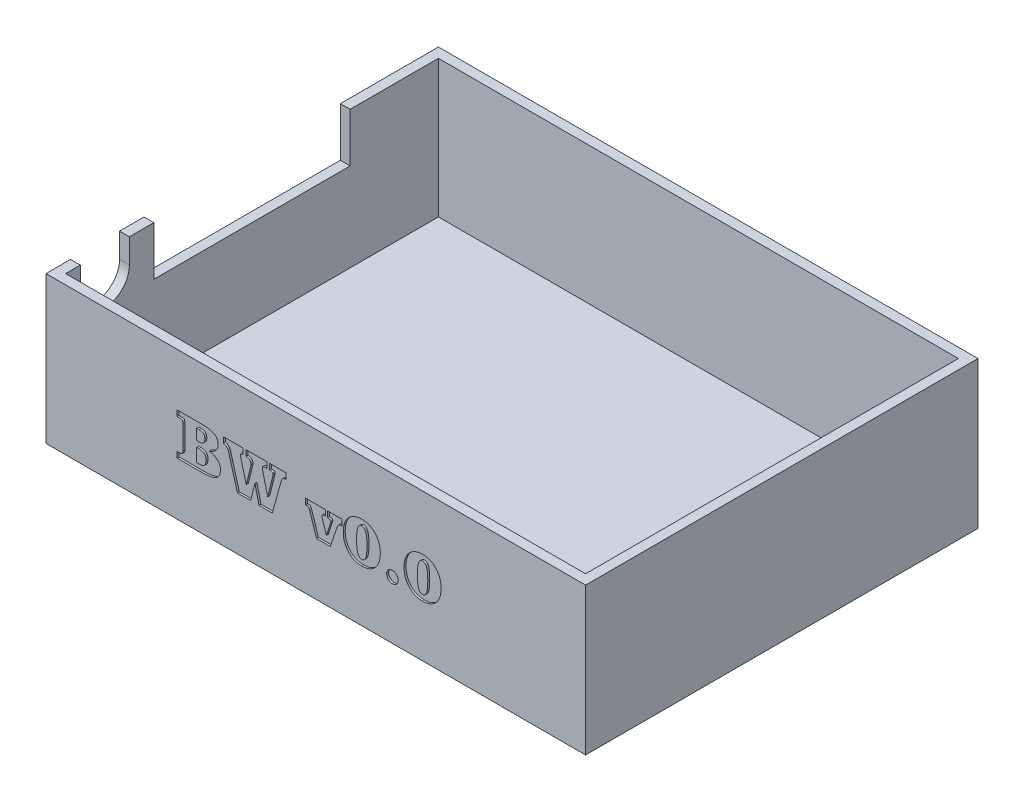
from build123d import *

# Parameters (mm, degrees)
SKETCH1_W           = 110
SKETCH1_H           = 80
BOSS_EXTRUDE1_DEPTH = 30
SHELL1_T            = -2
CUT_EXTRUDE1_REACH  = 112
SKETCH15_W          = 40
SKETCH15_H          = 10
CUT_EXTRUDE2_REACH  = 112
CUT_EXTRUDE3_DEPTH  = 0.4


with BuildPart() as part:
    # Sketch1 → Boss-Extrude1 (new body)
    with BuildSketch(Plane(origin=(0, 0, 0), x_dir=(1, 0, 0), z_dir=(0, 1, 0))):
        with Locations((55, 40)):
            Rectangle(SKETCH1_W, SKETCH1_H)
    extrude(amount=BOSS_EXTRUDE1_DEPTH)

    # Shell1
    shell1_openings = [part.faces().sort_by_distance(p)[0] for p in [
        (55, 30, -40),
    ]]
    offset(amount=SHELL1_T, openings=shell1_openings, kind=Kind.INTERSECTION)

    # Sketch15 → Cut-Extrude1 (cut, up to next)
    with BuildSketch(Plane.ZY, mode=Mode.PRIVATE) as cut_extrude1_sk1:
        with Locations((-40, 25)):
            Rectangle(SKETCH15_W, SKETCH15_H)
    cut_extrude1_tool1 = extrude(cut_extrude1_sk1.sketch, amount=-CUT_EXTRUDE1_REACH, mode=Mode.PRIVATE) & part.part
    add(cut_extrude1_tool1.solids().sort_by_distance((0, 25, -40))[0], mode=Mode.SUBTRACT)

    # Sketch17 → Cut-Extrude2 (cut, up to next)
    with BuildSketch(Plane.ZY, mode=Mode.PRIVATE) as cut_extrude2_sk1:
        with BuildLine():
            Line((-5, 25), (-5, 30))
            Line((-5, 30), (-15, 30))
            Line((-15, 30), (-15, 25))
            ThreePointArc((-15, 25), (-10, 20), (-5, 25))
        make_face()
    cut_extrude2_tool1 = extrude(cut_extrude2_sk1.sketch, amount=-CUT_EXTRUDE2_REACH, mode=Mode.PRIVATE) & part.part
    add(cut_extrude2_tool1.solids().sort_by_distance((0, 25.466749, -10))[0], mode=Mode.SUBTRACT)

    # Sketch19 → Cut-Extrude3 (cut)
    with BuildSketch(Plane.XY):
        with BuildLine():
            Line((26.714769787, 10.78656484), (26.714769787, 11.980032722))
            Line((26.714769787, 11.980032722), (27.16670121, 11.980032722))
            add(Edge.make_bspline(
                [(27.16670121, 11.980032722), (27.235036267, 11.980341078), (27.359170057, 11.980901222), (27.525767484, 12.002206712), (27.655496277, 12.027902602), (27.757390003, 12.072839446), (27.82752873, 12.159463619), (27.867385276, 12.285759373), (27.891107838, 12.453780677), (27.893814382, 12.580648302), (27.895325342, 12.651473694)],
                knots=[0, 0, 0, 0, 0.000204827, 0.000372078, 0.000502734, 0.000601727, 0.000698565, 0.000826377, 0.000994389, 0.001206721, 0.001206721, 0.001206721, 0.001206721], degree=3))
            Line((27.895325342, 12.651473694), (27.895325342, 12.714190708))
            Line((27.895325342, 12.714190708), (27.895325342, 17.399520569))
            add(Edge.make_bspline(
                [(27.895325342, 17.399520569), (27.894633353, 17.472179333), (27.893384356, 17.603323647), (27.868731245, 17.776515565), (27.831793135, 17.906345783), (27.769557231, 18.000539309), (27.667544151, 18.052053507), (27.533936365, 18.084063364), (27.357746728, 18.102291212), (27.226371785, 18.104686126), (27.153788884, 18.106009285)],
                knots=[0, 0, 0, 0, 0.00021779, 0.000393097, 0.000523178, 0.00062096, 0.000720945, 0.000856521, 0.001032931, 0.001250721, 0.001250721, 0.001250721, 0.001250721], degree=3))
            Line((27.153788884, 18.106009285), (26.714769787, 18.106009285))
            Line((26.714769787, 18.106009285), (26.714769787, 19.28656484))
            Line((26.714769787, 19.28656484), (31.857564926, 19.28656484))
            add(Edge.make_bspline(
                [(31.857564926, 19.28656484), (31.992257434, 19.285256135), (32.253226736, 19.282720495), (32.630489994, 19.260285256), (32.98051086, 19.225060022), (33.301647483, 19.17063196), (33.596445836, 19.106368052), (33.861940887, 19.023004466), (34.101219841, 18.927745549), (34.312454752, 18.815453835), (34.498439525, 18.686326055), (34.660278143, 18.541458122), (34.794000196, 18.375714122), (34.906670416, 18.196361763), (34.990564187, 17.997774513), (35.055229769, 17.784266098), (35.088599224, 17.551817585), (35.09395615, 17.391616063), (35.096714231, 17.309134285)],
                knots=[0, 0, 0, 0, 0.000404039, 0.000782833, 0.001133412, 0.001458803, 0.001759521, 0.002037814, 0.002292665, 0.002531164, 0.002753759, 0.002970531, 0.003180267, 0.003390659, 0.003603806, 0.003825014, 0.00405824, 0.004305755, 0.004305755, 0.004305755, 0.004305755], degree=3))
            add(Edge.make_bspline(
                [(35.096714231, 17.309134285), (35.095383355, 17.251868314), (35.092754336, 17.138744862), (35.069241365, 16.972276946), (35.035210863, 16.811430624), (34.984764193, 16.65613805), (34.918166047, 16.507751202), (34.838655463, 16.365078213), (34.745097156, 16.228378213), (34.636566194, 16.098548136), (34.515050542, 15.975123594), (34.380277332, 15.859515195), (34.232872869, 15.75110716), (34.072743877, 15.649748059), (33.89896586, 15.557304477), (33.714001293, 15.470771917), (33.514607859, 15.393065418), (33.376525485, 15.347653944), (33.305590099, 15.324325257)],
                knots=[0, 0, 0, 0, 0.000171708, 0.000339193, 0.000503457, 0.000664458, 0.000827964, 0.000990646, 0.001153861, 0.001324146, 0.001497629, 0.001672897, 0.001856258, 0.002046119, 0.00224089, 0.002446381, 0.002658416, 0.002882413, 0.002882413, 0.002882413, 0.002882413], degree=3))
            add(Edge.make_bspline(
                [(33.305590099, 15.324325257), (33.398119091, 15.303972249), (33.578281699, 15.264343036), (33.836139297, 15.187165882), (34.077792257, 15.105350011), (34.299927869, 15.011410982), (34.504541052, 14.90932463), (34.691957585, 14.800246424), (34.857838276, 14.676532304), (35.009563144, 14.548246607), (35.140484262, 14.406588081), (35.255936615, 14.257259066), (35.353018069, 14.096346414), (35.43228044, 13.925019269), (35.492799177, 13.742874368), (35.537757894, 13.551629801), (35.563407312, 13.349435625), (35.567065156, 13.211078749), (35.568936453, 13.140297479)],
                knots=[0, 0, 0, 0, 0.000284125, 0.000553218, 0.000806979, 0.001049193, 0.001276051, 0.001492753, 0.001698624, 0.001896102, 0.002087951, 0.002276111, 0.002461493, 0.002650492, 0.002841238, 0.003036323, 0.003239038, 0.00345137, 0.00345137, 0.00345137, 0.00345137], degree=3))
            add(Edge.make_bspline(
                [(35.568936453, 13.140297479), (35.566975999, 13.03867375), (35.563178896, 12.84184395), (35.5193464, 12.55868263), (35.451555252, 12.297256854), (35.356739614, 12.057052988), (35.228514673, 11.841380844), (35.077435572, 11.645243502), (34.895495241, 11.47417459), (34.685714891, 11.324824868), (34.442878212, 11.196564383), (34.164751657, 11.087094513), (33.849799806, 10.993962902), (33.497894129, 10.916627686), (33.108229669, 10.859334434), (32.681622835, 10.817602654), (32.218195873, 10.791765955), (31.89695161, 10.788341492), (31.73028628, 10.78656484)],
                knots=[0, 0, 0, 0, 0.000304636, 0.000590033, 0.000857147, 0.001113708, 0.001361739, 0.001607488, 0.001854095, 0.002107983, 0.00237784, 0.002675848, 0.00300324, 0.003362178, 0.003755843, 0.004184057, 0.004647776, 0.005147752, 0.005147752, 0.005147752, 0.005147752], degree=3))
            Line((31.73028628, 10.78656484), (26.714769787, 10.78656484))
        make_face()
        with BuildLine():
            Line((30.728658676, 11.967120396), (31.241462495, 11.967120396))
            add(Edge.make_bspline(
                [(31.241462495, 11.967120396), (31.30051387, 11.968317745), (31.415117069, 11.970641485), (31.580479253, 11.984579937), (31.732706013, 12.010676713), (31.87162286, 12.045424665), (31.998223504, 12.089161674), (32.111880992, 12.144536301), (32.211910094, 12.211456878), (32.300969919, 12.288077945), (32.37637685, 12.377678255), (32.44271057, 12.478730252), (32.494639248, 12.594743557), (32.541345666, 12.721288653), (32.57646004, 12.861638957), (32.599250492, 13.014867074), (32.614304462, 13.181198901), (32.616441099, 13.296439861), (32.617547565, 13.356117792)],
                knots=[0, 0, 0, 0, 0.00017717, 0.00034384, 0.000497287, 0.000640004, 0.000773021, 0.000898415, 0.00101813, 0.001133179, 0.001249624, 0.001368326, 0.001494585, 0.00162996, 0.001772677, 0.001927647, 0.002094317, 0.00227333, 0.00227333, 0.00227333, 0.00227333], degree=3))
            add(Edge.make_bspline(
                [(32.617547565, 13.356117792), (32.616321155, 13.410861647), (32.613946368, 13.516866247), (32.600373543, 13.670766056), (32.572001556, 13.813080324), (32.53513352, 13.944446943), (32.490604703, 14.065869514), (32.429458409, 14.173338326), (32.3618981, 14.272315329), (32.281735744, 14.359806332), (32.189981564, 14.435789224), (32.088288935, 14.502848948), (31.973888931, 14.558098498), (31.848068677, 14.604681559), (31.709236856, 14.63844973), (31.559584269, 14.664753227), (31.397911653, 14.678970118), (31.286373176, 14.681227775), (31.228550169, 14.682398174)],
                knots=[0, 0, 0, 0, 0.000164264, 0.000318077, 0.000462783, 0.000598847, 0.00072731, 0.000849501, 0.000968733, 0.001086239, 0.001204093, 0.001325348, 0.001450741, 0.001584384, 0.0017271, 0.00187873, 0.002039889, 0.002213371, 0.002213371, 0.002213371, 0.002213371], degree=3))
            Line((31.228550169, 14.682398174), (30.728658676, 14.682398174))
            Line((30.728658676, 14.682398174), (30.728658676, 11.967120396))
        make_face(mode=Mode.SUBTRACT)
        with BuildLine():
            Line((30.728658676, 15.862953729), (31.165833155, 15.862953729))
            add(Edge.make_bspline(
                [(31.165833155, 15.862953729), (31.216895862, 15.863470322), (31.315511541, 15.864468002), (31.458560146, 15.877532229), (31.590441668, 15.899424437), (31.712205294, 15.928783842), (31.823171545, 15.96698828), (31.923006349, 16.015360879), (32.013017414, 16.070489922), (32.117420831, 16.157889234), (32.227104505, 16.294185495), (32.320409995, 16.495659036), (32.371794332, 16.736011605), (32.378094027, 16.907991266), (32.381436453, 16.999238451)],
                knots=[0, 0, 0, 0, 0.000153148, 0.000295769, 0.000430414, 0.000553893, 0.000671153, 0.000781707, 0.00088612, 0.000986968, 0.001188918, 0.001405108, 0.001647204, 0.00192083, 0.00192083, 0.00192083, 0.00192083], degree=3))
            add(Edge.make_bspline(
                [(32.381436453, 16.999238451), (32.378949196, 17.089309413), (32.37430039, 17.25765645), (32.322753356, 17.490478007), (32.239229428, 17.68427574), (32.136416255, 17.813879048), (32.036518675, 17.892092697), (31.952687696, 17.945417433), (31.855657682, 17.986606469), (31.747732357, 18.022105474), (31.628397901, 18.04870623), (31.497900779, 18.069715851), (31.355993406, 18.07991448), (31.257461079, 18.081307548), (31.206414752, 18.08202925)],
                knots=[0, 0, 0, 0, 0.000269825, 0.000504317, 0.000710716, 0.000898261, 0.000992751, 0.001090516, 0.0011954, 0.001307982, 0.001431034, 0.001561741, 0.001704208, 0.001857355, 0.001857355, 0.001857355, 0.001857355], degree=3))
            Line((31.206414752, 18.08202925), (30.728658676, 18.08202925))
            Line((30.728658676, 18.08202925), (30.728658676, 15.862953729))
        make_face(mode=Mode.SUBTRACT)
        with BuildLine():
            Line((40.17310312, 19.28656484), (40.17310312, 18.106009285))
            add(Edge.make_bspline(
                [(40.17310312, 18.106009285), (40.126963818, 18.104746399), (40.041860154, 18.102417015), (39.924146066, 18.090949668), (39.827968582, 18.068350193), (39.752406155, 18.034831459), (39.694736375, 17.990612218), (39.654988496, 17.932591364), (39.630032122, 17.86198193), (39.628112903, 17.810483171), (39.627096176, 17.783201125)],
                knots=[0, 0, 0, 0, 0.000138457, 0.000255383, 0.000354255, 0.000433488, 0.000501764, 0.000569313, 0.000641654, 0.000723152, 0.000723152, 0.000723152, 0.000723152], degree=3))
            add(Edge.make_bspline(
                [(39.627096176, 17.783201125), (39.627965417, 17.754283116), (39.629689643, 17.696921413), (39.638547185, 17.612284069), (39.654964207, 17.531435606), (39.670951632, 17.479955564), (39.678745481, 17.454859111)],
                knots=[0, 0, 0, 0, 8.6776e-05, 0.000172128, 0.000254971, 0.000333774, 0.000333774, 0.000333774, 0.000333774], degree=3))
            Line((39.678745481, 17.454859111), (40.831631766, 13.136608243))
            Line((40.831631766, 13.136608243), (41.829570134, 17.163409458))
            add(Edge.make_bspline(
                [(41.829570134, 17.163409458), (41.812939889, 17.248074658), (41.782172869, 17.404710715), (41.713759846, 17.6154942), (41.628532419, 17.782124284), (41.521051327, 17.908957992), (41.382395008, 17.997746063), (41.209133808, 18.055943704), (40.999453087, 18.096594811), (40.846004924, 18.102714268), (40.763380898, 18.106009285)],
                knots=[0, 0, 0, 0, 0.000258701, 0.000478613, 0.000662641, 0.000816906, 0.000971414, 0.001149971, 0.001362327, 0.001610062, 0.001610062, 0.001610062, 0.001610062], degree=3))
            Line((40.763380898, 18.106009285), (40.763380898, 19.28656484))
            Line((40.763380898, 19.28656484), (45.013380898, 19.28656484))
            Line((45.013380898, 19.28656484), (45.013380898, 18.106009285))
            Line((45.013380898, 18.106009285), (44.731154335, 18.106009285))
            add(Edge.make_bspline(
                [(44.731154335, 18.106009285), (44.672695696, 18.105869823), (44.565998333, 18.105615279), (44.421674322, 18.09046751), (44.307991602, 18.070410238), (44.221411853, 18.040620894), (44.160957874, 17.994166189), (44.118182543, 17.936502731), (44.094234429, 17.863635925), (44.092166565, 17.81104299), (44.09107187, 17.783201125)],
                knots=[0, 0, 0, 0, 0.000175278, 0.000319913, 0.000434591, 0.000521601, 0.000591332, 0.000659956, 0.000734039, 0.000817374, 0.000817374, 0.000817374, 0.000817374], degree=3))
            add(Edge.make_bspline(
                [(44.09107187, 17.783201125), (44.091376854, 17.760441782), (44.092004877, 17.713575818), (44.099267837, 17.63927741), (44.118663576, 17.552914186), (44.133981571, 17.490480393), (44.142721176, 17.454859111)],
                knots=[0, 0, 0, 0, 6.8276e-05, 0.000140593, 0.000223437, 0.000333497, 0.000333497, 0.000333497, 0.000333497], degree=3))
            Line((44.142721176, 17.454859111), (45.194153467, 13.136608243))
            Line((45.194153467, 13.136608243), (46.27325503, 17.467771437))
            add(Edge.make_bspline(
                [(46.27325503, 17.467771437), (46.281092158, 17.497800516), (46.296029678, 17.55503576), (46.310237912, 17.638410047), (46.320162277, 17.713493258), (46.322138596, 17.761040407), (46.323059717, 17.783201125)],
                knots=[0, 0, 0, 0, 9.3057e-05, 0.000177367, 0.000253556, 0.000320065, 0.000320065, 0.000320065, 0.000320065], degree=3))
            add(Edge.make_bspline(
                [(46.323059717, 17.783201125), (46.321268115, 17.812256604), (46.317954152, 17.86600109), (46.294083077, 17.94151977), (46.248270351, 17.999812701), (46.182310366, 18.044507673), (46.088550452, 18.072259272), (45.961789012, 18.09328367), (45.795680326, 18.104755977), (45.671917809, 18.105563763), (45.603658676, 18.106009285)],
                knots=[0, 0, 0, 0, 8.7186e-05, 0.00016127, 0.000233588, 0.00030522, 0.000396803, 0.000524175, 0.000690692, 0.000895478, 0.000895478, 0.000895478, 0.000895478], degree=3))
            Line((45.603658676, 18.106009285), (45.603658676, 19.28656484))
            Line((45.603658676, 19.28656484), (48.909214231, 19.28656484))
            Line((48.909214231, 19.28656484), (48.909214231, 18.106009285))
            add(Edge.make_bspline(
                [(48.909214231, 18.106009285), (48.845091242, 18.104278351), (48.723143176, 18.10098649), (48.55225203, 18.066049532), (48.404889832, 18.009014243), (48.278299733, 17.927266337), (48.174845387, 17.811530447), (48.081644255, 17.66687669), (48.00226365, 17.486212518), (47.959749156, 17.352628755), (47.937100516, 17.281465014)],
                knots=[0, 0, 0, 0, 0.000192159, 0.000365445, 0.000520272, 0.000664034, 0.000812821, 0.000982175, 0.00117865, 0.001402648, 0.001402648, 0.001402648, 0.001402648], degree=3))
            Line((47.937100516, 17.281465014), (46.133064058, 10.78656484))
            Line((46.133064058, 10.78656484), (43.434387842, 10.78656484))
            Line((43.434387842, 10.78656484), (42.587708155, 14.254446785))
            Line((42.587708155, 14.254446785), (41.717048433, 10.78656484))
            Line((41.717048433, 10.78656484), (39.018372217, 10.78656484))
            Line((39.018372217, 10.78656484), (37.243849648, 17.050887757))
            add(Edge.make_bspline(
                [(37.243849648, 17.050887757), (37.216948412, 17.138330535), (37.166394506, 17.302656589), (37.065302076, 17.523145835), (36.958784365, 17.707937497), (36.833882431, 17.852735557), (36.693774166, 17.96358269), (36.533658472, 18.042633588), (36.353366761, 18.092960394), (36.225340845, 18.101564949), (36.159214231, 18.106009285)],
                knots=[0, 0, 0, 0, 0.00027416, 0.000515213, 0.000726218, 0.000911894, 0.001085327, 0.001258564, 0.001444294, 0.001642708, 0.001642708, 0.001642708, 0.001642708], degree=3))
            Line((36.159214231, 18.106009285), (36.159214231, 19.28656484))
            Line((36.159214231, 19.28656484), (40.17310312, 19.28656484))
        make_face()
        with BuildLine():
            add(Edge.make_bspline(
                [(58.032695134, 15.031030986), (58.039360552, 15.048713985), (58.052035815, 15.082340783), (58.06241358, 15.134063394), (58.070883869, 15.183849973), (58.071249986, 15.217299334), (58.071432113, 15.233938972)],
                knots=[0, 0, 0, 0, 5.6585e-05, 0.000107605, 0.000157953, 0.000207792, 0.000207792, 0.000207792, 0.000207792], degree=3))
            add(Edge.make_bspline(
                [(58.071432113, 15.233938972), (58.069896102, 15.263706906), (58.066970552, 15.320404159), (58.037974025, 15.399919178), (57.988955071, 15.46636349), (57.917473983, 15.517704372), (57.825639807, 15.557871132), (57.710253848, 15.59039149), (57.568522654, 15.613268348), (57.465245985, 15.622068293), (57.409214231, 15.626842618)],
                knots=[0, 0, 0, 0, 8.9021e-05, 0.000169553, 0.000249979, 0.000332987, 0.000430385, 0.000549474, 0.000691701, 0.00086038, 0.00086038, 0.00086038, 0.00086038], degree=3))
            Line((57.409214231, 15.626842618), (57.409214231, 16.807398174))
            Line((57.409214231, 16.807398174), (60.36060312, 16.807398174))
            Line((60.36060312, 16.807398174), (60.36060312, 15.621308764))
            Line((60.36060312, 15.621308764), (60.310798433, 15.621308764))
            add(Edge.make_bspline(
                [(60.310798433, 15.621308764), (60.25104752, 15.619701212), (60.137593109, 15.61664881), (59.976982035, 15.589588729), (59.836942366, 15.542236022), (59.715772728, 15.473684309), (59.611349784, 15.381843184), (59.520516271, 15.264189368), (59.439144503, 15.121365685), (59.397502173, 15.013852833), (59.375577078, 14.957246264)],
                knots=[0, 0, 0, 0, 0.000179166, 0.000340198, 0.000486621, 0.000620467, 0.000755124, 0.000900896, 0.001064486, 0.001246393, 0.001246393, 0.001246393, 0.001246393], degree=3))
            Line((59.375577078, 14.957246264), (57.933085759, 10.78656484))
            Line((57.933085759, 10.78656484), (55.149557113, 10.78656484))
            Line((55.149557113, 10.78656484), (53.756870481, 15.031030986))
            add(Edge.make_bspline(
                [(53.756870481, 15.031030986), (53.738671179, 15.089129634), (53.705550153, 15.19486374), (53.648740213, 15.33489642), (53.592283024, 15.441464547), (53.529460476, 15.517025388), (53.45698929, 15.566492446), (53.372054655, 15.599763204), (53.270545833, 15.61672147), (53.19800621, 15.619710384), (53.159214231, 15.621308764)],
                knots=[0, 0, 0, 0, 0.00018258, 0.000332278, 0.000452858, 0.000543093, 0.000623941, 0.000713344, 0.000814647, 0.000931091, 0.000931091, 0.000931091, 0.000931091], degree=3))
            Line((53.159214231, 15.621308764), (52.92310312, 15.621308764))
            Line((52.92310312, 15.621308764), (52.92310312, 16.807398174))
            Line((52.92310312, 16.807398174), (56.936992009, 16.807398174))
            Line((56.936992009, 16.807398174), (56.936992009, 15.621308764))
            Line((56.936992009, 15.621308764), (56.752530203, 15.621308764))
            add(Edge.make_bspline(
                [(56.752530203, 15.621308764), (56.708182232, 15.62118044), (56.626564938, 15.620944276), (56.514968575, 15.60516745), (56.422676373, 15.58532104), (56.349559953, 15.552064639), (56.29362927, 15.505349327), (56.256462104, 15.443683753), (56.233599051, 15.368315559), (56.23159061, 15.313447657), (56.230503294, 15.28374366)],
                knots=[0, 0, 0, 0, 0.000132864, 0.00024452, 0.000337578, 0.000415139, 0.000483165, 0.000552774, 0.000628042, 0.000716891, 0.000716891, 0.000716891, 0.000716891], degree=3))
            add(Edge.make_bspline(
                [(56.230503294, 15.28374366), (56.231329849, 15.265870006), (56.233110122, 15.227372907), (56.244912627, 15.166843296), (56.263776191, 15.100576226), (56.279466662, 15.054939019), (56.287686453, 15.031030986)],
                knots=[0, 0, 0, 0, 5.3621e-05, 0.000115491, 0.000184412, 0.000260244, 0.000260244, 0.000260244, 0.000260244], degree=3))
            Line((56.287686453, 15.031030986), (57.162035412, 12.36186866))
            Line((57.162035412, 12.36186866), (58.032695134, 15.031030986))
        make_face()
        with BuildLine():
            add(Edge.make_bspline(
                [(60.596714231, 14.678708937), (60.59995773, 14.830700288), (60.606290877, 15.127473478), (60.65408796, 15.56156039), (60.737241319, 15.971825304), (60.851705824, 16.359642126), (60.997477739, 16.725255984), (61.176709176, 17.068146352), (61.390575791, 17.387437775), (61.634994156, 17.681510663), (61.906226182, 17.946609076), (62.197275065, 18.181405427), (62.51314591, 18.375804464), (62.847112825, 18.537382828), (63.203444043, 18.660695877), (63.578037773, 18.752006028), (63.974639053, 18.803251246), (64.245226905, 18.810587756), (64.383715099, 18.814342618)],
                knots=[0, 0, 0, 0, 0.000455923, 0.00089022, 0.001308053, 0.001710184, 0.002101704, 0.002487022, 0.00286868, 0.003252471, 0.003632055, 0.004004832, 0.004371841, 0.004742284, 0.005115654, 0.005500865, 0.005897149, 0.006312598, 0.006312598, 0.006312598, 0.006312598], degree=3))
            add(Edge.make_bspline(
                [(64.383715099, 18.814342618), (64.520396855, 18.8108025), (64.788685622, 18.803853703), (65.181011122, 18.749176402), (65.553806715, 18.661110209), (65.906814332, 18.537356605), (66.239439467, 18.376151635), (66.550120173, 18.17633682), (66.844258379, 17.94532396), (67.113149552, 17.677542279), (67.359099187, 17.383677789), (67.571935463, 17.062907593), (67.750454148, 16.71971561), (67.900986912, 16.355793251), (68.010313902, 15.96691911), (68.095246563, 15.557991917), (68.142602435, 15.125604928), (68.148995378, 14.830076164), (68.152269787, 14.678708937)],
                knots=[0, 0, 0, 0, 0.00040992, 0.000804621, 0.001185815, 0.001557445, 0.001924566, 0.002291978, 0.002663608, 0.003044485, 0.003428276, 0.003811469, 0.004196786, 0.004587288, 0.00499067, 0.005406695, 0.005839159, 0.006293239, 0.006293239, 0.006293239, 0.006293239], degree=3))
            add(Edge.make_bspline(
                [(68.152269787, 14.678708937), (68.149002284, 14.527339576), (68.142622824, 14.231806642), (68.095170732, 13.79944941), (68.010702843, 13.390994166), (67.900214977, 13.002505405), (67.750875822, 12.638177326), (67.572461548, 12.294742063), (67.358384926, 11.975495312), (67.113895459, 11.681579541), (66.843423686, 11.416086624), (66.550218848, 11.183391245), (66.235838559, 10.98722493), (65.900027843, 10.82769743), (65.544921733, 10.701427753), (65.167578781, 10.613151274), (64.770060309, 10.561576316), (64.498233317, 10.554207968), (64.359735065, 10.550453729)],
                knots=[0, 0, 0, 0, 0.00045408, 0.000886543, 0.001302569, 0.001704179, 0.002096389, 0.002481707, 0.002863365, 0.003247156, 0.00362674, 0.00399837, 0.00436792, 0.004735902, 0.005111625, 0.005496408, 0.00589635, 0.006311798, 0.006311798, 0.006311798, 0.006311798], degree=3))
            add(Edge.make_bspline(
                [(64.359735065, 10.550453729), (64.223072958, 10.554185044), (63.954904695, 10.561506899), (63.562381861, 10.613456996), (63.189646462, 10.700882674), (62.838438121, 10.829113776), (62.504493687, 10.986094975), (62.192905805, 11.184042444), (61.90178169, 11.416664736), (61.631246032, 11.680930646), (61.38888144, 11.976135468), (61.174773435, 12.294727319), (60.995625304, 12.637710566), (60.849989139, 13.003330583), (60.735075707, 13.390327476), (60.65469898, 13.799777257), (60.606119408, 14.23175097), (60.59989984, 14.527320719), (60.596714231, 14.678708937)],
                knots=[0, 0, 0, 0, 0.00040992, 0.000804376, 0.001185569, 0.001556081, 0.001924062, 0.002290487, 0.002660672, 0.003040256, 0.003422871, 0.003804528, 0.004189846, 0.004581366, 0.004983497, 0.005399159, 0.005831622, 0.006285702, 0.006285702, 0.006285702, 0.006285702], degree=3))
        make_face()
        with BuildLine():
            add(Edge.make_bspline(
                [(65.436992009, 14.678708937), (65.436258015, 14.8041467), (65.434840091, 15.046466374), (65.424771754, 15.396538735), (65.403363104, 15.719306464), (65.379373677, 16.015509608), (65.34386187, 16.284302254), (65.303183579, 16.526752074), (65.250533404, 16.741205918), (65.19477678, 16.931316996), (65.128619654, 17.096514972), (65.052904282, 17.239662038), (64.965402295, 17.359521052), (64.872082048, 17.462221671), (64.764743451, 17.538991559), (64.648225521, 17.592893463), (64.522841353, 17.627938934), (64.435599585, 17.631811493), (64.391093571, 17.633787062)],
                knots=[0, 0, 0, 0, 0.00037632, 0.000726972, 0.001050418, 0.001346684, 0.001618269, 0.00186361, 0.002083731, 0.00228038, 0.002457473, 0.002616763, 0.002764724, 0.002901736, 0.003031254, 0.003157512, 0.003285484, 0.003418757, 0.003418757, 0.003418757, 0.003418757], degree=3))
            add(Edge.make_bspline(
                [(64.391093571, 17.633787062), (64.344818456, 17.631599496), (64.254836781, 17.627345786), (64.124068932, 17.595773944), (64.005113229, 17.538570553), (63.894235657, 17.462579471), (63.796417565, 17.362229473), (63.706448498, 17.242346153), (63.628250559, 17.099788605), (63.55978736, 16.935118948), (63.501070733, 16.745999969), (63.44988392, 16.530940419), (63.409265551, 16.288470726), (63.37124732, 16.019898701), (63.344408349, 15.723159145), (63.327590758, 15.398862898), (63.313179855, 15.047756543), (63.312397775, 14.80477502), (63.311992009, 14.678708937)],
                knots=[0, 0, 0, 0, 0.000138788, 0.000269873, 0.000400255, 0.000532785, 0.000671046, 0.000818615, 0.000981298, 0.001157389, 0.001352822, 0.001574737, 0.001820078, 0.00209008, 0.00238835, 0.002713526, 0.003064241, 0.003442406, 0.003442406, 0.003442406, 0.003442406], degree=3))
            add(Edge.make_bspline(
                [(63.311992009, 14.678708937), (63.312389926, 14.552641424), (63.313156876, 14.309657142), (63.327647049, 13.959183279), (63.344040248, 13.636046906), (63.372545378, 13.340246454), (63.40576742, 13.070942235), (63.451004526, 12.829410144), (63.498847402, 12.614265319), (63.558068701, 12.426028273), (63.62608776, 12.26205195), (63.703479684, 12.120645871), (63.79001804, 11.999966874), (63.889174918, 11.903684792), (63.99621942, 11.824990124), (64.114483132, 11.769599523), (64.243680372, 11.737330002), (64.332496385, 11.733156193), (64.378181245, 11.731009285)],
                knots=[0, 0, 0, 0, 0.000378165, 0.00072888, 0.001052215, 0.001348648, 0.001620233, 0.0018659, 0.002085595, 0.002281029, 0.00245712, 0.002617294, 0.002763764, 0.002900726, 0.003030244, 0.003160626, 0.003289921, 0.00342687, 0.00342687, 0.00342687, 0.00342687], degree=3))
            add(Edge.make_bspline(
                [(64.378181245, 11.731009285), (64.423869145, 11.733143701), (64.512691068, 11.737293225), (64.64104794, 11.769537152), (64.759262006, 11.823918807), (64.866963276, 11.900687812), (64.964428078, 11.998854393), (65.050554067, 12.118396245), (65.128743849, 12.257907233), (65.19464324, 12.420587261), (65.251198729, 12.608010705), (65.30283579, 12.82090664), (65.34410821, 13.06261306), (65.379437461, 13.331455854), (65.403347913, 13.628889489), (65.424822866, 13.954115516), (65.434827234, 14.307263446), (65.436253795, 14.552041643), (65.436992009, 14.678708937)],
                knots=[0, 0, 0, 0, 0.00013695, 0.000266244, 0.000394176, 0.000525196, 0.000660847, 0.000807318, 0.00096588, 0.001139558, 0.00133268, 0.001552801, 0.001796325, 0.002067911, 0.002366015, 0.002691301, 0.003045641, 0.00342565, 0.00342565, 0.00342565, 0.00342565], degree=3))
        make_face(mode=Mode.SUBTRACT)
        with BuildLine():
            add(Edge.make_bspline(
                [(69.450880898, 11.734698521), (69.455170765, 11.814439036), (69.463526788, 11.969761666), (69.528175277, 12.193400309), (69.638002845, 12.396154299), (69.787066113, 12.575353223), (69.966600222, 12.725006346), (70.171011269, 12.834223665), (70.396987352, 12.899108355), (70.554148513, 12.907329105), (70.63512569, 12.91156484)],
                knots=[0, 0, 0, 0, 0.000238983, 0.000465503, 0.000691633, 0.000926161, 0.001160688, 0.001388445, 0.001616738, 0.001859395, 0.001859395, 0.001859395, 0.001859395], degree=3))
            add(Edge.make_bspline(
                [(70.63512569, 12.91156484), (70.715475064, 12.907259916), (70.871994376, 12.898873993), (71.096944372, 12.834590723), (71.300162819, 12.724991866), (71.477525425, 12.574647898), (71.627353706, 12.396794652), (71.733607677, 12.192490086), (71.802372059, 11.970282179), (71.808731748, 11.814539298), (71.811992009, 11.734698521)],
                knots=[0, 0, 0, 0, 0.00024082, 0.000469113, 0.000695243, 0.000928352, 0.001162879, 0.001388142, 0.00161518, 0.001853999, 0.001853999, 0.001853999, 0.001853999], degree=3))
            add(Edge.make_bspline(
                [(71.811992009, 11.734698521), (71.808790178, 11.653620391), (71.802567254, 11.496040825), (71.733554386, 11.271493215), (71.62792346, 11.065522917), (71.477466905, 10.887403127), (71.300177927, 10.737018325), (71.096940359, 10.627430072), (70.871995448, 10.563143982), (70.715475428, 10.554758451), (70.63512569, 10.550453729)],
                knots=[0, 0, 0, 0, 0.000242495, 0.000471302, 0.000698198, 0.000932726, 0.001165835, 0.001391964, 0.001620257, 0.001861077, 0.001861077, 0.001861077, 0.001861077], degree=3))
            add(Edge.make_bspline(
                [(70.63512569, 10.550453729), (70.554148134, 10.554689251), (70.396986238, 10.562909586), (70.171015414, 10.627797246), (69.966584491, 10.737003336), (69.787126803, 10.886699634), (69.637430505, 11.066157322), (69.528224415, 11.270588246), (69.463336754, 11.496559069), (69.455116419, 11.653720965), (69.450880898, 11.734698521)],
                knots=[0, 0, 0, 0, 0.000242657, 0.00047095, 0.000698706, 0.000933234, 0.001167762, 0.001395518, 0.001623811, 0.001866468, 0.001866468, 0.001866468, 0.001866468], degree=3))
        make_face()
        with BuildLine():
            add(Edge.make_bspline(
                [(72.992547565, 14.678708937), (72.995791063, 14.830700288), (73.00212421, 15.127473478), (73.049921293, 15.56156039), (73.133074652, 15.971825304), (73.247539157, 16.359642126), (73.393311072, 16.725255984), (73.572542509, 17.068146352), (73.786409125, 17.387437775), (74.030827489, 17.681510663), (74.302059516, 17.946609076), (74.593108399, 18.181405427), (74.908979243, 18.375804464), (75.242946158, 18.537382828), (75.599277376, 18.660695877), (75.973871107, 18.752006028), (76.370472387, 18.803251246), (76.641060238, 18.810587756), (76.779548433, 18.814342618)],
                knots=[0, 0, 0, 0, 0.000455923, 0.00089022, 0.001308053, 0.001710184, 0.002101704, 0.002487022, 0.00286868, 0.003252471, 0.003632055, 0.004004832, 0.004371841, 0.004742284, 0.005115654, 0.005500865, 0.005897149, 0.006312598, 0.006312598, 0.006312598, 0.006312598], degree=3))
            add(Edge.make_bspline(
                [(76.779548433, 18.814342618), (76.916230188, 18.8108025), (77.184518955, 18.803853703), (77.576844455, 18.749176402), (77.949640048, 18.661110209), (78.302647666, 18.537356605), (78.635272801, 18.376151635), (78.945953507, 18.17633682), (79.240091713, 17.94532396), (79.508982885, 17.677542279), (79.75493252, 17.383677789), (79.967768796, 17.062907593), (80.146287481, 16.71971561), (80.296820246, 16.355793251), (80.406147235, 15.96691911), (80.491079897, 15.557991917), (80.538435769, 15.125604928), (80.544828711, 14.830076164), (80.54810312, 14.678708937)],
                knots=[0, 0, 0, 0, 0.00040992, 0.000804621, 0.001185815, 0.001557445, 0.001924566, 0.002291978, 0.002663608, 0.003044485, 0.003428276, 0.003811469, 0.004196786, 0.004587288, 0.00499067, 0.005406695, 0.005839159, 0.006293239, 0.006293239, 0.006293239, 0.006293239], degree=3))
            add(Edge.make_bspline(
                [(80.54810312, 14.678708937), (80.544835617, 14.527339576), (80.538456157, 14.231806642), (80.491004065, 13.79944941), (80.406536176, 13.390994166), (80.29604831, 13.002505405), (80.146709155, 12.638177326), (79.968294882, 12.294742063), (79.754218259, 11.975495312), (79.509728793, 11.681579541), (79.239257019, 11.416086624), (78.946052181, 11.183391245), (78.631671892, 10.98722493), (78.295861176, 10.82769743), (77.940755066, 10.701427753), (77.563412115, 10.613151274), (77.165893642, 10.561576316), (76.89406665, 10.554207968), (76.755568398, 10.550453729)],
                knots=[0, 0, 0, 0, 0.00045408, 0.000886543, 0.001302569, 0.001704179, 0.002096389, 0.002481707, 0.002863365, 0.003247156, 0.00362674, 0.00399837, 0.00436792, 0.004735902, 0.005111625, 0.005496408, 0.00589635, 0.006311798, 0.006311798, 0.006311798, 0.006311798], degree=3))
            add(Edge.make_bspline(
                [(76.755568398, 10.550453729), (76.618906291, 10.554185044), (76.350738028, 10.561506899), (75.958215194, 10.613456996), (75.585479795, 10.700882674), (75.234271454, 10.829113776), (74.900327021, 10.986094975), (74.588739138, 11.184042444), (74.297615024, 11.416664736), (74.027079365, 11.680930646), (73.784714773, 11.976135468), (73.570606769, 12.294727319), (73.391458637, 12.637710566), (73.245822472, 13.003330583), (73.13090904, 13.390327476), (73.050532313, 13.799777257), (73.001952742, 14.23175097), (72.995733173, 14.527320719), (72.992547565, 14.678708937)],
                knots=[0, 0, 0, 0, 0.00040992, 0.000804376, 0.001185569, 0.001556081, 0.001924062, 0.002290487, 0.002660672, 0.003040256, 0.003422871, 0.003804528, 0.004189846, 0.004581366, 0.004983497, 0.005399159, 0.005831622, 0.006285702, 0.006285702, 0.006285702, 0.006285702], degree=3))
        make_face()
        with BuildLine():
            add(Edge.make_bspline(
                [(77.832825342, 14.678708937), (77.832091348, 14.8041467), (77.830673424, 15.046466374), (77.820605087, 15.396538735), (77.799196438, 15.719306464), (77.775207011, 16.015509608), (77.739695204, 16.284302254), (77.699016912, 16.526752074), (77.646366738, 16.741205918), (77.590610113, 16.931316996), (77.524452987, 17.096514972), (77.448737616, 17.239662038), (77.361235629, 17.359521052), (77.267915381, 17.462221671), (77.160576784, 17.538991559), (77.044058854, 17.592893463), (76.918674686, 17.627938934), (76.831432918, 17.631811493), (76.786926905, 17.633787062)],
                knots=[0, 0, 0, 0, 0.00037632, 0.000726972, 0.001050418, 0.001346684, 0.001618269, 0.00186361, 0.002083731, 0.00228038, 0.002457473, 0.002616763, 0.002764724, 0.002901736, 0.003031254, 0.003157512, 0.003285484, 0.003418757, 0.003418757, 0.003418757, 0.003418757], degree=3))
            add(Edge.make_bspline(
                [(76.786926905, 17.633787062), (76.740651789, 17.631599496), (76.650670114, 17.627345786), (76.519902265, 17.595773944), (76.400946562, 17.538570553), (76.29006899, 17.462579471), (76.192250898, 17.362229473), (76.102281831, 17.242346153), (76.024083892, 17.099788605), (75.955620694, 16.935118948), (75.896904067, 16.745999969), (75.845717254, 16.530940419), (75.805098885, 16.288470726), (75.767080653, 16.019898701), (75.740241683, 15.723159145), (75.723424092, 15.398862898), (75.709013188, 15.047756543), (75.708231109, 14.80477502), (75.707825342, 14.678708937)],
                knots=[0, 0, 0, 0, 0.000138788, 0.000269873, 0.000400255, 0.000532785, 0.000671046, 0.000818615, 0.000981298, 0.001157389, 0.001352822, 0.001574737, 0.001820078, 0.00209008, 0.00238835, 0.002713526, 0.003064241, 0.003442406, 0.003442406, 0.003442406, 0.003442406], degree=3))
            add(Edge.make_bspline(
                [(75.707825342, 14.678708937), (75.708223259, 14.552641424), (75.708990209, 14.309657142), (75.723480382, 13.959183279), (75.739873581, 13.636046906), (75.768378711, 13.340246454), (75.801600753, 13.070942235), (75.846837859, 12.829410144), (75.894680735, 12.614265319), (75.953902034, 12.426028273), (76.021921094, 12.26205195), (76.099313017, 12.120645871), (76.185851373, 11.999966874), (76.285008251, 11.903684792), (76.392052753, 11.824990124), (76.510316466, 11.769599523), (76.639513705, 11.737330002), (76.728329719, 11.733156193), (76.774014578, 11.731009285)],
                knots=[0, 0, 0, 0, 0.000378165, 0.00072888, 0.001052215, 0.001348648, 0.001620233, 0.0018659, 0.002085595, 0.002281029, 0.00245712, 0.002617294, 0.002763764, 0.002900726, 0.003030244, 0.003160626, 0.003289921, 0.00342687, 0.00342687, 0.00342687, 0.00342687], degree=3))
            add(Edge.make_bspline(
                [(76.774014578, 11.731009285), (76.819702478, 11.733143701), (76.908524402, 11.737293225), (77.036881273, 11.769537152), (77.155095339, 11.823918807), (77.262796609, 11.900687812), (77.360261411, 11.998854393), (77.4463874, 12.118396245), (77.524577182, 12.257907233), (77.590476573, 12.420587261), (77.647032062, 12.608010705), (77.698669124, 12.82090664), (77.739941543, 13.06261306), (77.775270794, 13.331455854), (77.799181247, 13.628889489), (77.8206562, 13.954115516), (77.830660567, 14.307263446), (77.832087128, 14.552041643), (77.832825342, 14.678708937)],
                knots=[0, 0, 0, 0, 0.00013695, 0.000266244, 0.000394176, 0.000525196, 0.000660847, 0.000807318, 0.00096588, 0.001139558, 0.00133268, 0.001552801, 0.001796325, 0.002067911, 0.002366015, 0.002691301, 0.003045641, 0.00342565, 0.00342565, 0.00342565, 0.00342565], degree=3))
        make_face(mode=Mode.SUBTRACT)
    extrude(amount=-CUT_EXTRUDE3_DEPTH, mode=Mode.SUBTRACT)


solid = part.part
